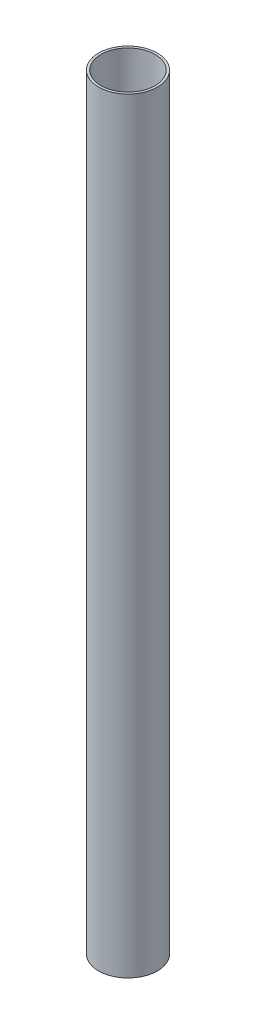
from build123d import *

# Parameters (mm, degrees)
CROQUIS1_R              = 25
CROQUIS1_R_2            = 23
SALIENTE_EXTRUIR1_DEPTH = 650


with BuildPart() as part:
    # Croquis1 → Saliente-Extruir1 (new body)
    with BuildSketch(Plane(origin=(0, 0, 0), x_dir=(1, 0, 0), z_dir=(0, 1, 0))):
        Circle(CROQUIS1_R)
        Circle(CROQUIS1_R_2, mode=Mode.SUBTRACT)
    extrude(amount=SALIENTE_EXTRUIR1_DEPTH)


solid = part.part
